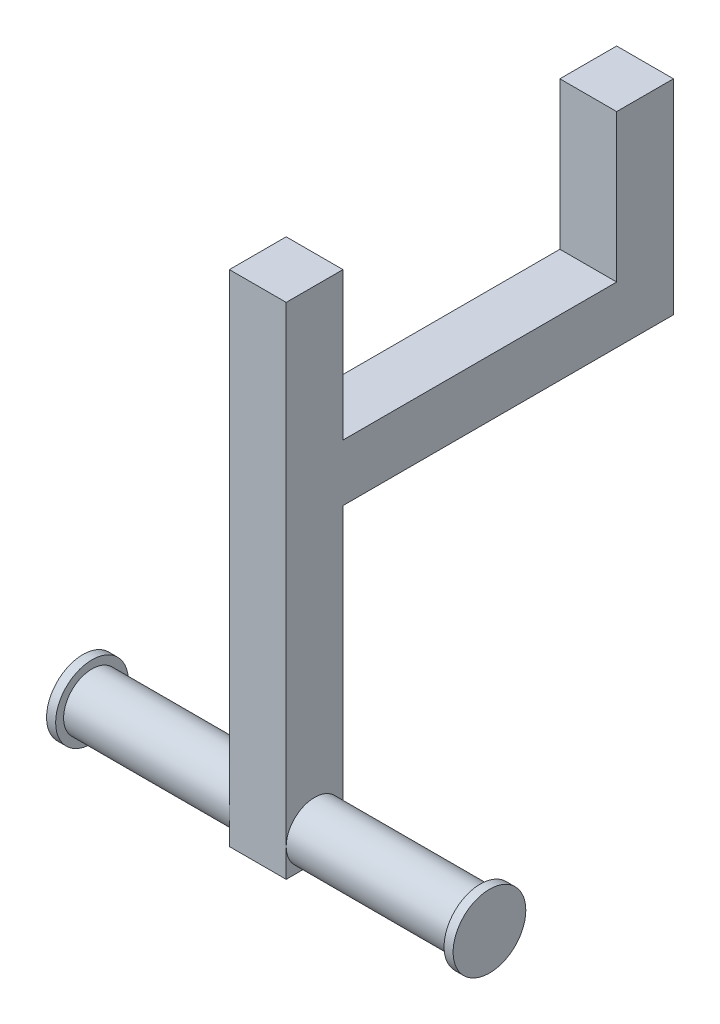
from build123d import *

# Parameters (mm, degrees)
SKETCH1_W                = 25
SKETCH1_H                = 170.5
BOSS_EXTRUDE1_DEPTH      = 25
SKETCH1_8_W              = 25
SKETCH1_8_H              = 25
BOSS_EXTRUDE2_DEPTH      = 90
BOSS_EXTRUDE3_DEPTH      = 90
BOSS_EXTRUDE3_DEPTH_BACK = 130
SKETCH1_9_W              = 25
SKETCH1_9_H              = 25
BOSS_EXTRUDE4_DEPTH      = 75
BOSS_EXTRUDE4_DEPTH_BACK = 100
SKETCH2_R                = 12.5
BOSS_EXTRUDE5_DEPTH      = 2
BOSS_EXTRUDE5_DEPTH_BACK = 2
SKETCH3_R                = 16
BOSS_EXTRUDE6_DEPTH      = 2
BOSS_EXTRUDE6_DEPTH_BACK = 2
SKETCH4_R                = 16


with BuildPart() as part:
    # Sketch1 → Boss-Extrude1 (new body)
    with BuildSketch(Plane(origin=(0, 0, 0), x_dir=(1, 0, 0), z_dir=(0, 1, 0))):
        with Locations((-72.566666667, -14.316666667)):
            Rectangle(SKETCH1_W, SKETCH1_H)
    extrude(amount=BOSS_EXTRUDE1_DEPTH)

    # Sketch1_8 → Boss-Extrude2 (add)
    with BuildSketch(Plane(origin=(0, 0, 0), x_dir=(1, 0, 0), z_dir=(0, 1, 0))):
        with Locations((-72.566666667, 58.433333333)):
            Rectangle(SKETCH1_8_W, SKETCH1_8_H)
        with Locations((-72.566666667, -87.066666667)):
            Rectangle(SKETCH1_8_W, SKETCH1_8_H)
    extrude(amount=BOSS_EXTRUDE2_DEPTH)

    # Sketch1_9 → Boss-Extrude3 (add, two sides: drawn at the far end of the back side and taken through both)
    with BuildSketch(Plane(origin=(0, 0, 0), x_dir=(1, 0, 0), z_dir=(0, 1, 0)).offset(-BOSS_EXTRUDE3_DEPTH_BACK)):
        with Locations((-72.566666667, -87.066666667)):
            Rectangle(SKETCH1_9_W, SKETCH1_9_H)
    extrude(amount=BOSS_EXTRUDE3_DEPTH + BOSS_EXTRUDE3_DEPTH_BACK)

    # Sketch2 → Boss-Extrude4 (add, two sides: drawn at the far end of the back side and taken through both)
    with BuildSketch(Plane(origin=(-60.066666667, 0, 0), x_dir=(0, 0, -1), z_dir=(1, 0, 0)).offset(-BOSS_EXTRUDE4_DEPTH_BACK)):
        with Locations((-87.066666667, -117.5)):
            Circle(SKETCH2_R)
    extrude(amount=BOSS_EXTRUDE4_DEPTH + BOSS_EXTRUDE4_DEPTH_BACK)

    # Sketch3 → Boss-Extrude5 (add, two sides: drawn at the far end of the back side and taken through both)
    with BuildSketch(Plane(origin=(14.933333333, 0, 0), x_dir=(0, 0, -1), z_dir=(1, 0, 0)).offset(-BOSS_EXTRUDE5_DEPTH_BACK)):
        with Locations((-87.066666667, -117.5)):
            Circle(SKETCH3_R)
    extrude(amount=BOSS_EXTRUDE5_DEPTH + BOSS_EXTRUDE5_DEPTH_BACK)

    # Sketch4 → Boss-Extrude6 (add, two sides: drawn at the far end of the back side and taken through both)
    with BuildSketch(Plane.ZY.offset(160.066666667).offset(-BOSS_EXTRUDE6_DEPTH_BACK)):
        with Locations((87.066666667, -117.5)):
            Circle(SKETCH4_R)
    extrude(amount=BOSS_EXTRUDE6_DEPTH + BOSS_EXTRUDE6_DEPTH_BACK)


solid = part.part
